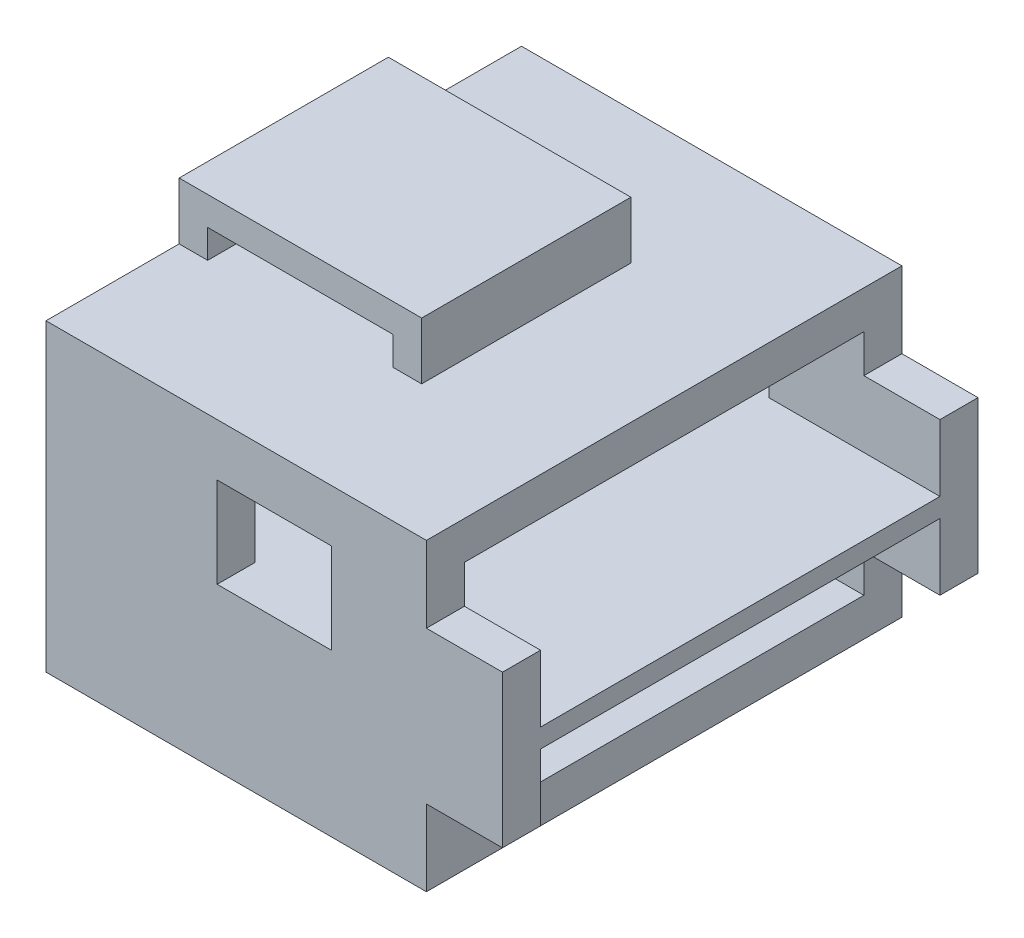
from build123d import *

# Parameters (mm, degrees)
CROQUIS1_W              = 20
CROQUIS1_H              = 25
SALIENTE_EXTRUIR4_DEPTH = 16
CORTAR_EXTRUIR1_START   = 10
CROQUIS4_W              = 21
CROQUIS4_H              = 12
CORTAR_EXTRUIR1_DEPTH   = 18
SALIENTE_EXTRUIR6_START = -10
CROQUIS5_W              = 21
CROQUIS5_H              = 1
SALIENTE_EXTRUIR6_DEPTH = 24
SALIENTE_EXTRUIR7_START = 10
CROQUIS7_W              = 2
CROQUIS7_H              = 8
SALIENTE_EXTRUIR7_DEPTH = 4
SALIENTE_EXTRUIR8_START = 16
CROQUIS8_W              = 12.75
CROQUIS8_H              = 11
SALIENTE_EXTRUIR8_DEPTH = 3
CROQUIS9_W              = 9.75
CROQUIS9_H              = 1.5
CORTAR_EXTRUIR2_DEPTH   = 11.5
CROQUIS11_W             = 6
CROQUIS11_H             = 4.75
CORTAR_EXTRUIR4_DEPTH   = 16.5
CROQUIS12_W             = 6
CROQUIS12_H             = 4.75
CORTAR_EXTRUIR5_DEPTH   = 33


with BuildPart() as part:
    # Croquis1 → Saliente-Extruir4 (new body)
    with BuildSketch(Plane(origin=(0, 0, 0), x_dir=(1, 0, 0), z_dir=(0, 1, 0))):
        Rectangle(CROQUIS1_W, CROQUIS1_H)
    extrude(amount=SALIENTE_EXTRUIR4_DEPTH)

    # Croquis4 → Cortar-Extruir1 (cut)
    with BuildSketch(Plane(origin=(0, 0, 0), x_dir=(0, 0, -1), z_dir=(1, 0, 0)).offset(CORTAR_EXTRUIR1_START)):
        with Locations((0, 8)):
            Rectangle(CROQUIS4_W, CROQUIS4_H)
    extrude(amount=-CORTAR_EXTRUIR1_DEPTH, mode=Mode.SUBTRACT)

    # Croquis5 → Saliente-Extruir6 (add)
    with BuildSketch(Plane(origin=(0, 0, 0), x_dir=(0, 0, -1), z_dir=(1, 0, 0)).offset(SALIENTE_EXTRUIR6_START)):
        with Locations((0, 8)):
            Rectangle(CROQUIS5_W, CROQUIS5_H)
    extrude(amount=SALIENTE_EXTRUIR6_DEPTH)

    # Croquis7 → Saliente-Extruir7 (add)
    with BuildSketch(Plane(origin=(0, 0, 0), x_dir=(0, 0, -1), z_dir=(1, 0, 0)).offset(SALIENTE_EXTRUIR7_START)):
        with Locations((-11.5, 8)):
            Rectangle(CROQUIS7_W, CROQUIS7_H)
        with Locations((11.5, 8)):
            Rectangle(CROQUIS7_W, CROQUIS7_H)
    extrude(amount=SALIENTE_EXTRUIR7_DEPTH)

    # Croquis8 → Saliente-Extruir8 (add)
    with BuildSketch(Plane(origin=(0, 0, 0), x_dir=(1, 0, 0), z_dir=(0, 1, 0)).offset(SALIENTE_EXTRUIR8_START)):
        with Locations((-3.625, 0)):
            Rectangle(CROQUIS8_W, CROQUIS8_H)
    extrude(amount=SALIENTE_EXTRUIR8_DEPTH)

    # Croquis9 → Cortar-Extruir2 (cut, symmetric)
    with BuildSketch(Plane.XY):
        with Locations((-3.625, 16.75)):
            Rectangle(CROQUIS9_W, CROQUIS9_H)
    extrude(amount=CORTAR_EXTRUIR2_DEPTH, both=True, mode=Mode.SUBTRACT)

    # Croquis11 → Cortar-Extruir4 (cut, symmetric)
    with BuildSketch(Plane.XY):
        with Locations((2, 10.875)):
            Rectangle(CROQUIS11_W, CROQUIS11_H)
    extrude(amount=CORTAR_EXTRUIR4_DEPTH, both=True, mode=Mode.SUBTRACT)

    # Croquis12 → Cortar-Extruir5 (cut)
    with BuildSketch(Plane(origin=(0, 0, 0), x_dir=(0, 0, -1), z_dir=(1, 0, 0))):
        with Locations((0, 4.375)):
            Rectangle(CROQUIS12_W, CROQUIS12_H)
    extrude(amount=-CORTAR_EXTRUIR5_DEPTH, mode=Mode.SUBTRACT)


solid = part.part
